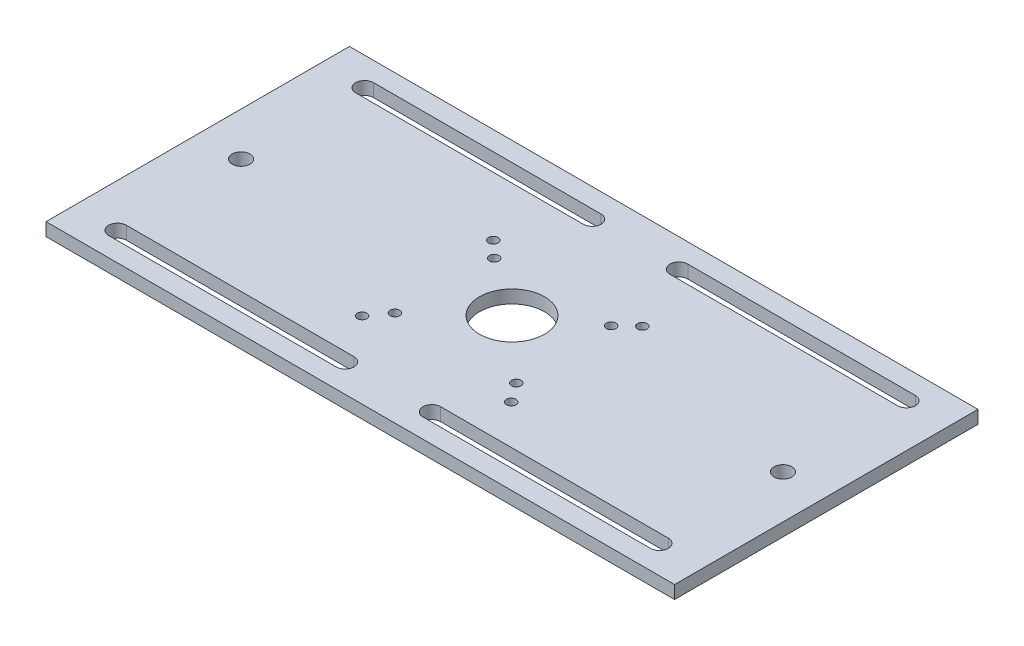
from build123d import *

# Parameters (mm, degrees)
SKETCH_1_W      = 290
SKETCH_1_H      = 140
SKETCH_1_R      = 4.1
SKETCH_1_R_2    = 15
SKETCH_1_R_3    = 2.2
EXTRUDE_1_DEPTH = 6


with BuildPart() as part:
    # Эскиз1 → Бобышка-Вытянуть1 (new body)
    with BuildSketch(Plane(origin=(0, 0, 0), x_dir=(1, 0, 0), z_dir=(0, 1, 0))):
        Rectangle(SKETCH_1_W, SKETCH_1_H)
        with Locations((-125, 0)):
            Circle(SKETCH_1_R, mode=Mode.SUBTRACT)
        with Locations((125, 0)):
            Circle(SKETCH_1_R, mode=Mode.SUBTRACT)
        Circle(SKETCH_1_R_2, mode=Mode.SUBTRACT)
        with Locations((-34.4, 25.75)):
            Circle(SKETCH_1_R_3, mode=Mode.SUBTRACT)
        with Locations((34.4, 25.75)):
            Circle(SKETCH_1_R_3, mode=Mode.SUBTRACT)
        with Locations((-28, -26)):
            Circle(SKETCH_1_R_3, mode=Mode.SUBTRACT)
        with Locations((-34.4, -34.75)):
            Circle(SKETCH_1_R_3, mode=Mode.SUBTRACT)
        with Locations((-27, 18.75)):
            Circle(SKETCH_1_R_3, mode=Mode.SUBTRACT)
        with Locations((28, -26)):
            Circle(SKETCH_1_R_3, mode=Mode.SUBTRACT)
        with Locations((27, 18.75)):
            Circle(SKETCH_1_R_3, mode=Mode.SUBTRACT)
        with Locations((34.4, -34.75)):
            Circle(SKETCH_1_R_3, mode=Mode.SUBTRACT)
        with BuildLine():
            Line((-125, 61.1), (-20, 61.1))
            ThreePointArc((-20, 61.1), (-15.9, 57), (-20, 52.9))
            Line((-20, 52.9), (-125, 52.9))
            ThreePointArc((-125, 52.9), (-129.1, 57), (-125, 61.1))
        make_face(mode=Mode.SUBTRACT)
        with BuildLine():
            Line((-125, -52.9), (-20, -52.9))
            ThreePointArc((-20, -52.9), (-15.9, -57), (-20, -61.1))
            Line((-20, -61.1), (-125, -61.1))
            ThreePointArc((-125, -61.1), (-129.1, -57), (-125, -52.9))
        make_face(mode=Mode.SUBTRACT)
        with BuildLine():
            Line((125, -61.1), (20, -61.1))
            ThreePointArc((20, -61.1), (15.9, -57), (20, -52.9))
            Line((20, -52.9), (125, -52.9))
            ThreePointArc((125, -52.9), (129.1, -57), (125, -61.1))
        make_face(mode=Mode.SUBTRACT)
        with BuildLine():
            Line((125, 52.9), (20, 52.9))
            ThreePointArc((20, 52.9), (15.9, 57), (20, 61.1))
            Line((20, 61.1), (125, 61.1))
            ThreePointArc((125, 61.1), (129.1, 57), (125, 52.9))
        make_face(mode=Mode.SUBTRACT)
    extrude(amount=EXTRUDE_1_DEPTH)


solid = part.part
